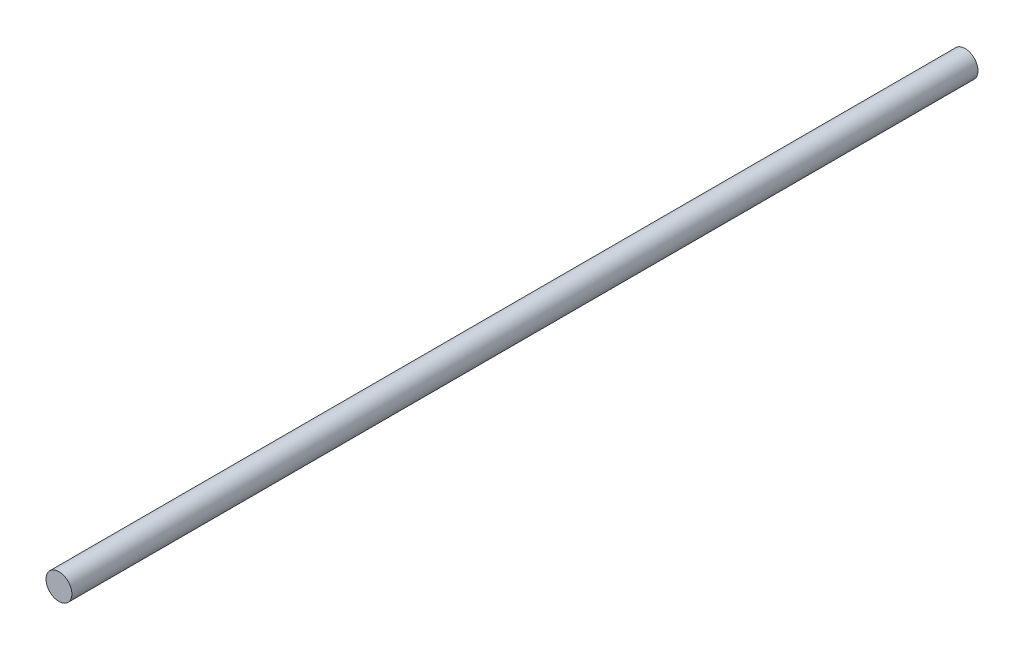
from build123d import *

# Parameters (mm, degrees)
SKETCH1_R           = 6.35
BOSS_EXTRUDE1_DEPTH = 444.5


with BuildPart() as part:
    # Sketch1 → Boss-Extrude1 (new body)
    with BuildSketch(Plane.XY):
        Circle(SKETCH1_R)
    extrude(amount=BOSS_EXTRUDE1_DEPTH)


solid = part.part
